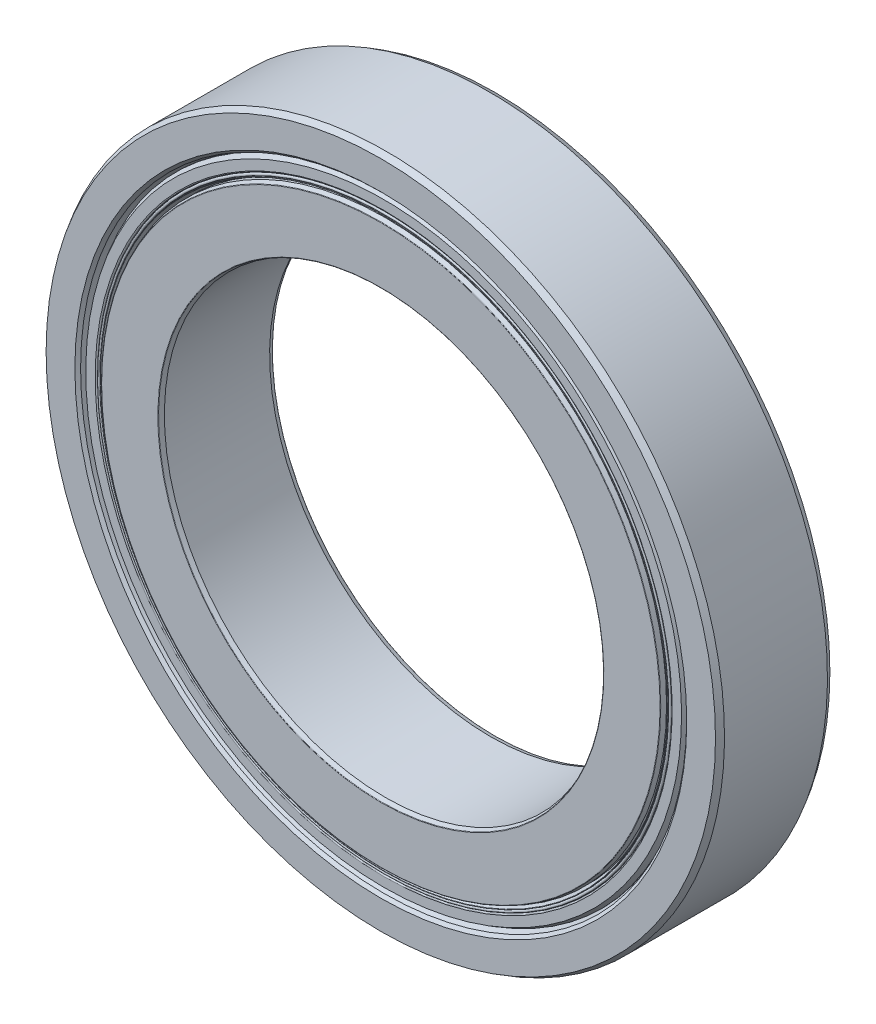
from build123d import *

# Parameters (mm, degrees)
CIRPATTERN1_COUNT = 6


with BuildPart() as part:
    # Sketch3 → Revolve1 (revolve)
    with BuildSketch(Plane(origin=(0, 0, 0), x_dir=(0, 0, -1), z_dir=(1, 0, 0))):
        with BuildLine():
            Line((-9.256430067, 57.85), (-10.45, 58.284423928))
            Line((-10.45, 58.284423928), (-11, 58.834423928))
            Line((-11, 58.834423928), (-11, 64.364914704))
            Line((-11, 64.364914704), (-9.9, 65))
            Line((-9.9, 65), (9.9, 65))
            Line((9.9, 65), (11, 64.364914704))
            Line((11, 64.364914704), (11, 58.834423928))
            Line((11, 58.834423928), (10.45, 58.284423928))
            Line((10.45, 58.284423928), (9.256430067, 57.85))
            Line((9.256430067, 57.85), (5.126, 57.85))
            ThreePointArc((5.126, 57.85), (0, 61.425), (-5.126, 57.85))
            Line((-5.126, 57.85), (-9.256430067, 57.85))
        make_face()
    revolve(axis=Axis((0, 0, 11), (0, 0, -1)))


with BuildPart() as body_2:
    # Sketch4 → Revolve2 (revolve)
    with BuildSketch(Plane(origin=(0, 0, 0), x_dir=(0, 0, -1), z_dir=(1, 0, 0))):
        with BuildLine():
            Line((-10.12, 42.5), (-10.927622216, 42.793950447))
            ThreePointArc((-10.927622216, 42.793950447), (-10.980106725, 42.834223227), (-11, 42.897316635))
            Line((-11, 42.897316635), (-11, 53.67778798))
            ThreePointArc((-11, 53.67778798), (-10.980106725, 53.740881388), (-10.927622216, 53.781154168))
            Line((-10.927622216, 53.781154168), (-10.12, 54.075104615))
            Line((-10.12, 54.075104615), (-5.126, 54.075104615))
            ThreePointArc((-5.126, 54.075104615), (0, 50.500104615), (5.126, 54.075104615))
            Line((5.126, 54.075104615), (10.12, 54.075104615))
            Line((10.12, 54.075104615), (10.927622216, 53.781154168))
            ThreePointArc((10.927622216, 53.781154168), (10.980106725, 53.740881388), (11, 53.67778798))
            Line((11, 53.67778798), (11, 42.897316635))
            ThreePointArc((11, 42.897316635), (10.980106725, 42.834223227), (10.927622216, 42.793950447))
            Line((10.927622216, 42.793950447), (10.12, 42.5))
            Line((10.12, 42.5), (-10.12, 42.5))
        make_face()
    revolve(axis=Axis((0, 0, 11), (0, 0, -1)))


with BuildPart() as body_3:
    # Sketch5 → Revolve3 (revolve)
    with BuildSketch(Plane(origin=(0, 0, 0), x_dir=(0, 0, -1), z_dir=(1, 0, 0))):
        with BuildLine():
            Line((-5.462447692, 55.962552308), (5.462447692, 55.962552308))
            ThreePointArc((5.462447692, 55.962552308), (0, 61.425), (-5.462447692, 55.962552308))
        make_face()
    revolve(axis=Axis((0, 55.962552308, 5.462447692), (0, 0, -1)))


with BuildPart() as cirpattern1_1:
    # CirPattern1: pattern copy
    add(body_3.part.rotate(Axis((0, 0, 0), (0, 0, 1)), 1 * 360 / CIRPATTERN1_COUNT))


with BuildPart() as cirpattern1_2:
    # CirPattern1: pattern copy
    add(body_3.part.rotate(Axis((0, 0, 0), (0, 0, 1)), 2 * 360 / CIRPATTERN1_COUNT))


with BuildPart() as cirpattern1_3:
    # CirPattern1: pattern copy
    add(body_3.part.rotate(Axis((0, 0, 0), (0, 0, 1)), 3 * 360 / CIRPATTERN1_COUNT))


with BuildPart() as cirpattern1_4:
    # CirPattern1: pattern copy
    add(body_3.part.rotate(Axis((0, 0, 0), (0, 0, 1)), 4 * 360 / CIRPATTERN1_COUNT))


with BuildPart() as cirpattern1_5:
    # CirPattern1: pattern copy
    add(body_3.part.rotate(Axis((0, 0, 0), (0, 0, 1)), 5 * 360 / CIRPATTERN1_COUNT))


with BuildPart() as body_9:
    # Sketch6 → Revolve4 (revolve)
    with BuildSketch(Plane(origin=(0, 0, 0), x_dir=(0, 0, -1), z_dir=(1, 0, 0))):
        with BuildLine():
            Line((-9.475721421, 57.85), (-5.462447692, 57.85))
            Line((-5.462447692, 57.85), (-5.462447692, 55.200104615))
            Line((-5.462447692, 55.200104615), (-10.16875, 55.200104615))
            ThreePointArc((-10.16875, 55.200104615), (-10.367623782, 55.282480833), (-10.45, 55.481354615))
            Line((-10.45, 55.481354615), (-10.45, 57.2875))
            Line((-10.45, 57.2875), (-9.475721421, 57.85))
        make_face()
        with BuildLine():
            Line((10.16875, 55.200104615), (5.462447692, 55.200104615))
            Line((5.462447692, 55.200104615), (5.462447692, 57.85))
            Line((5.462447692, 57.85), (9.475721421, 57.85))
            Line((9.475721421, 57.85), (10.45, 57.2875))
            Line((10.45, 57.2875), (10.45, 55.481354615))
            ThreePointArc((10.45, 55.481354615), (10.367623782, 55.282480833), (10.16875, 55.200104615))
        make_face()
    revolve(axis=Axis((0, 0, 11), (0, 0, -1)))


with BuildPart() as body_10:
    # Sketch7 → Revolve5 (revolve)
    with BuildSketch(Plane(origin=(0, 0, 0), x_dir=(0, 0, -1), z_dir=(1, 0, 0))):
        with BuildLine():
            Line((-5.462447692, 54.075104615), (-9.161464452, 54.075104615))
            Line((-9.161464452, 54.075104615), (-10.413811108, 54.530921521))
            ThreePointArc((-10.413811108, 54.530921521), (-10.449164426, 54.592155265), (-10.395, 54.637604615))
            Line((-10.395, 54.637604615), (-10.16875, 54.637604615))
            ThreePointArc((-10.16875, 54.637604615), (-10.45, 54.918854615), (-10.16875, 55.200104615))
            Line((-10.16875, 55.200104615), (-5.462447692, 55.200104615))
            Line((-5.462447692, 55.200104615), (-5.462447692, 54.075104615))
        make_face()
        with BuildLine():
            Line((5.462447692, 55.200104615), (5.462447692, 54.075104615))
            Line((5.462447692, 54.075104615), (9.161464452, 54.075104615))
            Line((9.161464452, 54.075104615), (10.413811108, 54.530921521))
            ThreePointArc((10.413811108, 54.530921521), (10.449164426, 54.592155265), (10.395, 54.637604615))
            Line((10.395, 54.637604615), (10.16875, 54.637604615))
            ThreePointArc((10.16875, 54.637604615), (10.45, 54.918854615), (10.16875, 55.200104615))
            Line((10.16875, 55.200104615), (5.462447692, 55.200104615))
        make_face()
    revolve(axis=Axis((0, 0, 11), (0, 0, -1)))


solid = Compound([part.part, body_2.part, body_3.part, cirpattern1_1.part, cirpattern1_2.part, cirpattern1_3.part, cirpattern1_4.part, cirpattern1_5.part, body_9.part, body_10.part])
